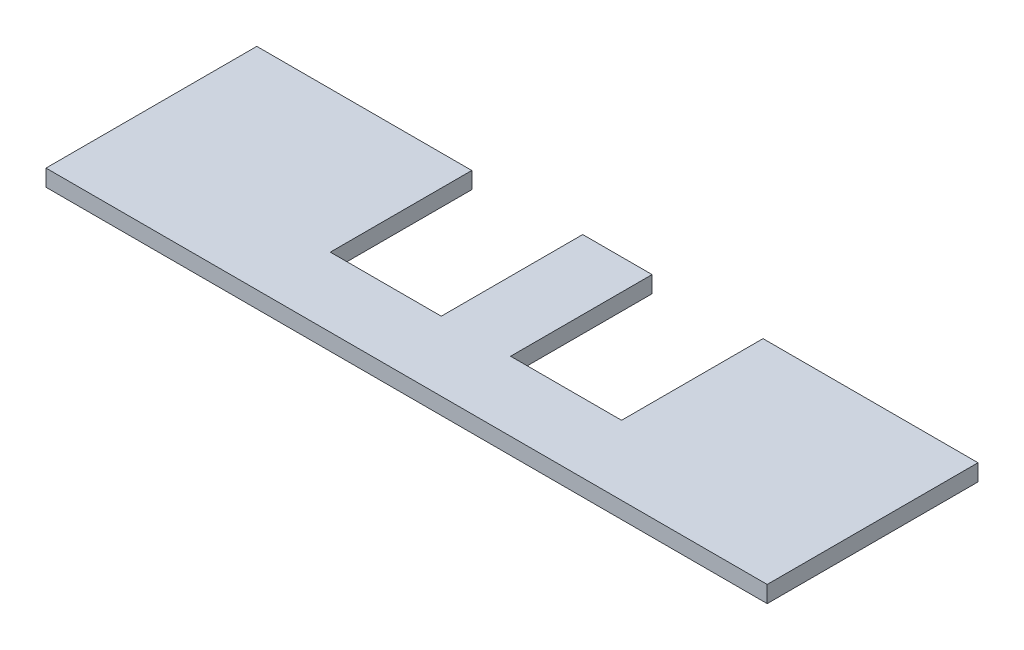
from build123d import *

# Parameters (mm, degrees)
SKETCH1_W               = 130
SKETCH1_H               = 120
BOSS_EXTRUDE1_DEPTH     = 3
CUT_EXTRUDE1_START      = -4
SKETCH2_W               = 20
SKETCH2_H               = 95
CUT_EXTRUDE1_DEPTH      = 5
CUT_EXTRUDE2_START      = -4
SKETCH3_R               = 1.6
CUT_EXTRUDE2_DEPTH      = 5
SKETCH4_W               = 130
SKETCH4_H               = 82
CUT_EXTRUDE3_DEPTH      = 1
CUT_EXTRUDE3_DEPTH_BACK = 4


with BuildPart() as part:
    # Sketch1 → Boss-Extrude1 (new body)
    with BuildSketch(Plane(origin=(0, 0, 0), x_dir=(1, 0, 0), z_dir=(0, 1, 0))):
        Rectangle(SKETCH1_W, SKETCH1_H)
    extrude(amount=BOSS_EXTRUDE1_DEPTH)

    # Sketch2 → Cut-Extrude1 (cut)
    with BuildSketch(Plane(origin=(0, 3, 0), x_dir=(1, 0, 0), z_dir=(0, 1, 0)).offset(CUT_EXTRUDE1_START)):
        with Locations((-16.25, 0)):
            Rectangle(SKETCH2_W, SKETCH2_H)
    cut_extrude1 = extrude(amount=CUT_EXTRUDE1_DEPTH, mode=Mode.SUBTRACT)

    # Mirror1: Cut-Extrude1 across plane
    add(cut_extrude1.mirror(Plane(origin=(0, 0, 0), x_dir=(0, 0, 1), z_dir=(1, 0, 0))), mode=Mode.SUBTRACT)

    # Sketch3 → Cut-Extrude2 (cut)
    with BuildSketch(Plane(origin=(0, 3, 0), x_dir=(1, 0, 0), z_dir=(0, 1, 0)).offset(CUT_EXTRUDE2_START)):
        with Locations((44.5, 0)):
            Circle(SKETCH3_R)
    cut_extrude2 = extrude(amount=CUT_EXTRUDE2_DEPTH, mode=Mode.SUBTRACT)

    # Mirror2: Cut-Extrude2 across plane
    add(cut_extrude2.mirror(Plane(origin=(0, 0, 0), x_dir=(0, 0, 1), z_dir=(1, 0, 0))), mode=Mode.SUBTRACT)

    # Sketch4 → Cut-Extrude3 (cut, two sides)
    with BuildSketch(Plane(origin=(0, 3, 0), x_dir=(1, 0, 0), z_dir=(0, 1, 0))) as cut_extrude3_sk:
        with Locations((0, 19)):
            Rectangle(SKETCH4_W, SKETCH4_H)
    extrude(amount=CUT_EXTRUDE3_DEPTH, mode=Mode.SUBTRACT)
    extrude(cut_extrude3_sk.sketch, amount=-CUT_EXTRUDE3_DEPTH_BACK, mode=Mode.SUBTRACT)


solid = part.part
